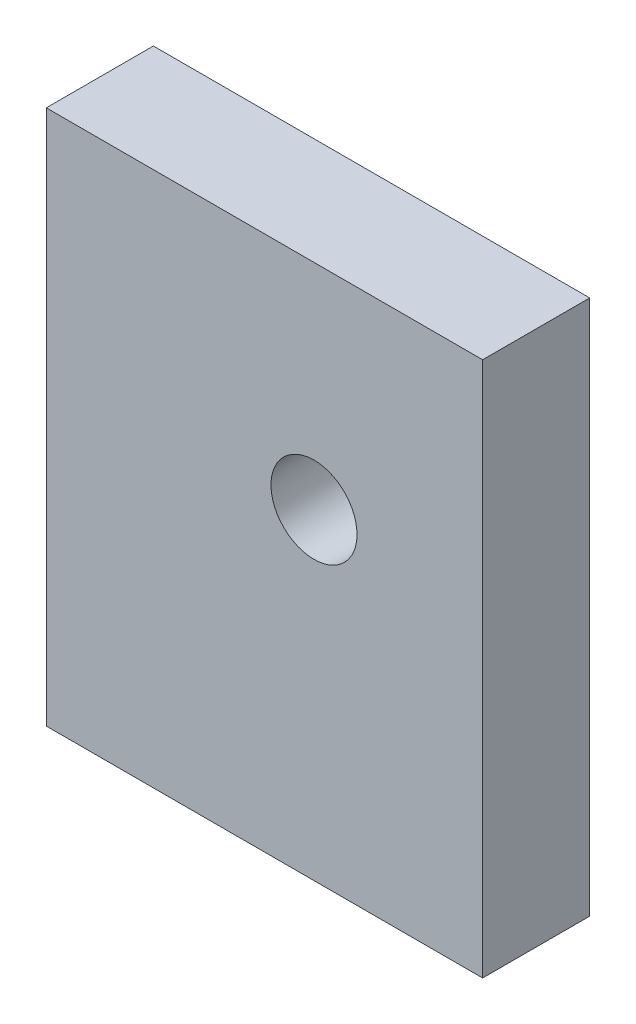
from build123d import *

# Parameters (mm, degrees)
SKETCH1_W             = 25.875
SKETCH1_H             = 31.75
BOSS_EXTRUDE1_DEPTH   = 6.35
SKETCH1_4_OUTSIDE_W   = 36.165
SKETCH1_4_OUTSIDE_H   = 42.04
SKETCH1_4_OUTSIDE_W_2 = 25.875
SKETCH1_4_OUTSIDE_H_2 = 31.75
SKETCH1_4_OUTSIDE_R   = 2.551011908
CUT_EXTRUDE3_DEPTH    = 71.705469941


with BuildPart() as part:
    # Sketch1 → Boss-Extrude1 (new body)
    with BuildSketch(Plane.XY):
        with Locations((-35.541307617, 35.200886597)):
            Rectangle(SKETCH1_W, SKETCH1_H)
    extrude(amount=BOSS_EXTRUDE1_DEPTH)

    # Sketch1_4 outside → Cut-Extrude3 (cut, through all)
    # profile 1 of 2: a face of its own
    with BuildSketch(Plane.XY):
        with Locations((-35.5415, 35.201)):
            Rectangle(SKETCH1_4_OUTSIDE_W, SKETCH1_4_OUTSIDE_H)
        with Locations((-35.541307617, 35.200886597)):
            Rectangle(SKETCH1_4_OUTSIDE_W_2, SKETCH1_4_OUTSIDE_H_2, mode=Mode.SUBTRACT)
    # profile 2 of 2: a face of its own
    with BuildSketch(Plane.XY):
        with Locations((-32.603807617, 38.375886597)):
            Circle(SKETCH1_4_OUTSIDE_R)
    extrude(amount=CUT_EXTRUDE3_DEPTH, mode=Mode.SUBTRACT)


solid = part.part
